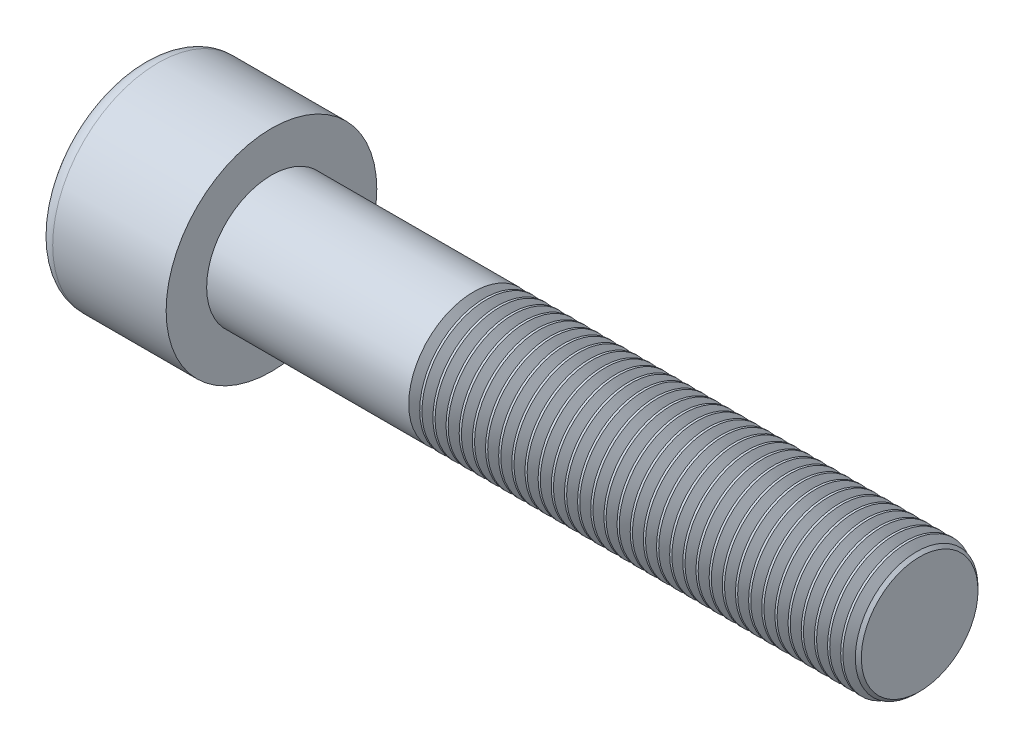
from build123d import *

# Parameters (mm, degrees)
SKETCH1_R           = 6.5
BASEHEAD_DEPTH      = 8
SKETCH2_R           = 4
BASEBODY_DEPTH      = 40
HEXAGONSOCKET_DEPTH = 4
TOPFILLET_R         = 1
CHAMFER1_SIZE       = 0.4
LPATTERN10_COUNT    = 34
LPATTERN10_PITCH    = 0.8118


with BuildPart() as part:
    # Sketch1 → BaseHead (new body)
    with BuildSketch(Plane(origin=(0, 0, 0), x_dir=(0, 0, -1), z_dir=(1, 0, 0))):
        Circle(SKETCH1_R)
    extrude(amount=BASEHEAD_DEPTH)

    # Sketch2 → BaseBody (add)
    with BuildSketch(Plane(origin=(8, 0, 0), x_dir=(0, 0, -1), z_dir=(1, 0, 0))):
        Circle(SKETCH2_R)
    extrude(amount=BASEBODY_DEPTH)

    # Sketch3 → HexagonSocket (cut)
    with BuildSketch(Plane(origin=(0, 0, 0), x_dir=(0, 0, -1), z_dir=(1, 0, 0))):
        Polygon((3.464101615, 0), (1.732050808, 3), (-1.732050808, 3), (-3.464101615, 0), (-1.732050808, -3), (1.732050808, -3), align=None)
    extrude(amount=HEXAGONSOCKET_DEPTH, mode=Mode.SUBTRACT)

    # Sketch4 → Cut-Revolve1 (revolve, cut)
    with BuildSketch(Plane(origin=(-4.19613823, 0.75, 0), x_dir=(-1, 0, 0), z_dir=(0, 0, 1))):
        Polygon((-8.19613823, 3.75), (-9.928189037, 0.75), (-8.19613823, 0.75), align=None)
    revolve(axis=Axis((0.838992387, 0, 0), (-1, 0, 0)), mode=Mode.SUBTRACT)

    # TopFillet
    topfillet_edges = [part.edges().sort_by_distance(p)[0] for p in [
        (0, 0, 6.5),
    ]]
    fillet(topfillet_edges, radius=TOPFILLET_R)

    # Chamfer1
    chamfer1_edges = [part.edges().sort_by_distance(p)[0] for p in [
        (48, 0, 4),
    ]]
    chamfer(chamfer1_edges, length=CHAMFER1_SIZE)

    # Sketch5 → Cut-Revolve10 (revolve, cut)
    with BuildSketch(Plane.XY):
        Polygon((47.6, 3.414133814), (47.93825, 4), (47.93825, 4.6765), (47.26175, 4.6765), (47.26175, 4), align=None)
    cut_revolve10 = revolve(axis=Axis((0, 0, 0), (1, 0, 0)), mode=Mode.SUBTRACT)

    # LPattern10: Cut-Revolve10 ×34
    with Locations(*[(-i * LPATTERN10_PITCH, 0, 0) for i in range(1, LPATTERN10_COUNT)]):
        add(cut_revolve10, mode=Mode.SUBTRACT)


solid = part.part
